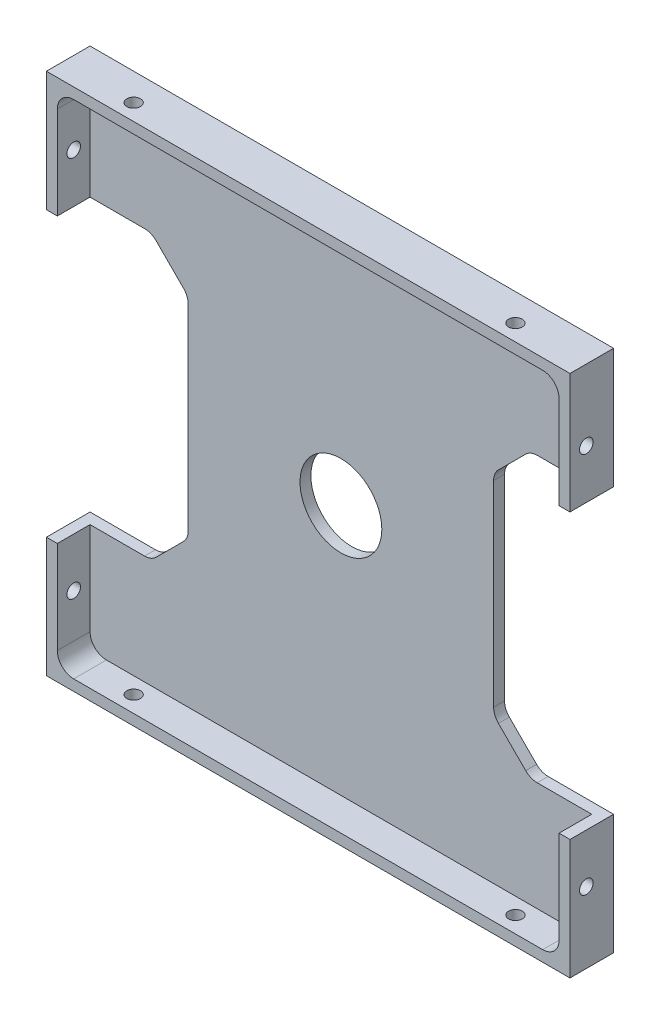
from build123d import *

# Parameters (mm, degrees)
SKETCH1_W                      = 96
SKETCH1_H                      = 96
BOSS_EXTRUDE1_DEPTH            = 8
SKETCH2_W                      = 92
SKETCH2_H                      = 92
COMPONENT_PLATFORM_DEPTH       = 6
CABLE_SLOTS_DEPTH              = 6
SKETCH4_R                      = 7.5
CENTER_MASS_CUT_DEPTH          = 6
INNER_CORNER_FILLETS_R         = 3
M3X0_5_TAPPED_HOLE1_AT_2_COUNT = 2
M3X0_5_TAPPED_HOLE1_AT_2_PITCH = 70
M3X0_5_TAPPED_HOLE2_AT_2_COUNT = 2
M3X0_5_TAPPED_HOLE2_AT_2_PITCH = 70


with BuildPart() as part:
    # Sketch1 → Boss-Extrude1 (new body)
    with BuildSketch(Plane.XY):
        Rectangle(SKETCH1_W, SKETCH1_H)
    extrude(amount=BOSS_EXTRUDE1_DEPTH)

    # Sketch2 → Component Platform (cut)
    with BuildSketch(Plane.XY.offset(8)):
        Rectangle(SKETCH2_W, SKETCH2_H)
    extrude(amount=-COMPONENT_PLATFORM_DEPTH, mode=Mode.SUBTRACT)

    # Sketch3 → Cable Slots (cut, symmetric)
    with BuildSketch(Plane.XY.offset(2)):
        with BuildLine():
            Line((-33.878679656, -25.121320344), (-28.878679656, -20.121320344))
            ThreePointArc((-28.878679656, -20.121320344), (-28.228361402, -19.148050297), (-28, -18))
            Line((-28, -18), (-28, 18))
            ThreePointArc((-28, 18), (-28.228361402, 19.148050297), (-28.878679656, 20.121320344))
            Line((-28.878679656, 20.121320344), (-33.878679656, 25.121320344))
            ThreePointArc((-33.878679656, 25.121320344), (-34.851949703, 25.771638598), (-36, 26))
            Line((-36, 26), (-48, 26))
            Line((-48, 26), (-48, -26))
            Line((-48, -26), (-36, -26))
            ThreePointArc((-36, -26), (-34.851949703, -25.771638598), (-33.878679656, -25.121320344))
        make_face()
        with BuildLine():
            Line((48, -26), (48, 26))
            Line((48, 26), (36, 26))
            ThreePointArc((36, 26), (34.851949703, 25.771638598), (33.878679656, 25.121320344))
            Line((33.878679656, 25.121320344), (28.878679656, 20.121320344))
            ThreePointArc((28.878679656, 20.121320344), (28.228361402, 19.148050297), (28, 18))
            Line((28, 18), (28, -18))
            ThreePointArc((28, -18), (28.228361402, -19.148050297), (28.878679656, -20.121320344))
            Line((28.878679656, -20.121320344), (33.878679656, -25.121320344))
            ThreePointArc((33.878679656, -25.121320344), (34.851949703, -25.771638598), (36, -26))
            Line((36, -26), (48, -26))
        make_face()
    extrude(amount=CABLE_SLOTS_DEPTH, both=True, mode=Mode.SUBTRACT)

    # Sketch4 → Center Mass Cut (cut)
    with BuildSketch(Plane.XY.offset(2)):
        Circle(SKETCH4_R)
    extrude(amount=-CENTER_MASS_CUT_DEPTH, mode=Mode.SUBTRACT)

    # Inner Corner Fillets
    inner_corner_fillets_edges = [part.edges().sort_by_distance(p)[0] for p in [
        (-46, -46, 5),
        (-46, 46, 5),
        (46, 46, 5),
        (46, -46, 5),
    ]]
    fillet(inner_corner_fillets_edges, radius=INNER_CORNER_FILLETS_R)

    # Sketch10 → M3x0.5 Tapped Hole1 (revolve, cut)
    with BuildSketch(Plane(origin=(48, -35, 5), x_dir=(0, 0, -1), z_dir=(0, 1, 0))):
        Polygon((0, 0), (0, 10.751075774), (1.25, 10), (1.25, 0), align=None)
    m3x0_5_tapped_hole1 = revolve(axis=Axis((54.35, -35, 5), (-1, 0, 0)), mode=Mode.SUBTRACT)

    # M3x0.5 Tapped Hole1 at 2: M3x0.5 Tapped Hole1 ×2
    with Locations(*[(0, i * M3X0_5_TAPPED_HOLE1_AT_2_PITCH, 0) for i in range(1, M3X0_5_TAPPED_HOLE1_AT_2_COUNT)]):
        add(m3x0_5_tapped_hole1, mode=Mode.SUBTRACT)

    # Sketch13 → M3x0.5 Tapped Hole2 (revolve, cut)
    with BuildSketch(Plane(origin=(-35, -48, 5), x_dir=(0, 0, -1), z_dir=(1, 0, 0))):
        Polygon((0, 0), (0, 10.751075774), (1.25, 10), (1.25, 0), align=None)
    m3x0_5_tapped_hole2 = revolve(axis=Axis((-35, -54.35, 5), (0, 1, 0)), mode=Mode.SUBTRACT)

    # M3x0.5 Tapped Hole2 at 2: M3x0.5 Tapped Hole2 ×2
    with Locations(*[(i * M3X0_5_TAPPED_HOLE2_AT_2_PITCH, 0, 0) for i in range(1, M3X0_5_TAPPED_HOLE2_AT_2_COUNT)]):
        add(m3x0_5_tapped_hole2, mode=Mode.SUBTRACT)

    # Mirror1: M3x0.5 Tapped Hole1 across plane
    add(m3x0_5_tapped_hole1.mirror(Plane(origin=(0, 0, 0), x_dir=(0, 0, 1), z_dir=(1, 0, 0))), mode=Mode.SUBTRACT)

    # Mirror1 copy 1 sketch → Mirror1 copy 1 (revolve, cut)
    with BuildSketch(Plane(origin=(-48, 35, 5), x_dir=(0, 0, -1), z_dir=(0, 1, 0))):
        Polygon((0, 0), (0, -10.751075774), (1.25, -10), (1.25, 0), align=None)
    revolve(axis=Axis((-54.35, 35, 5), (-1, 0, 0)), mode=Mode.SUBTRACT)

    # Mirror2: M3x0.5 Tapped Hole2 across plane
    add(m3x0_5_tapped_hole2.mirror(Plane(origin=(0, 0, 0), x_dir=(0, 0, 1), z_dir=(0, -1, 0))), mode=Mode.SUBTRACT)

    # Mirror2 copy 1 sketch → Mirror2 copy 1 (revolve, cut)
    with BuildSketch(Plane(origin=(35, 48, 5), x_dir=(0, 0, -1), z_dir=(1, 0, 0))):
        Polygon((0, 0), (0, -10.751075774), (1.25, -10), (1.25, 0), align=None)
    revolve(axis=Axis((35, 54.35, 5), (0, 1, 0)), mode=Mode.SUBTRACT)


solid = part.part
